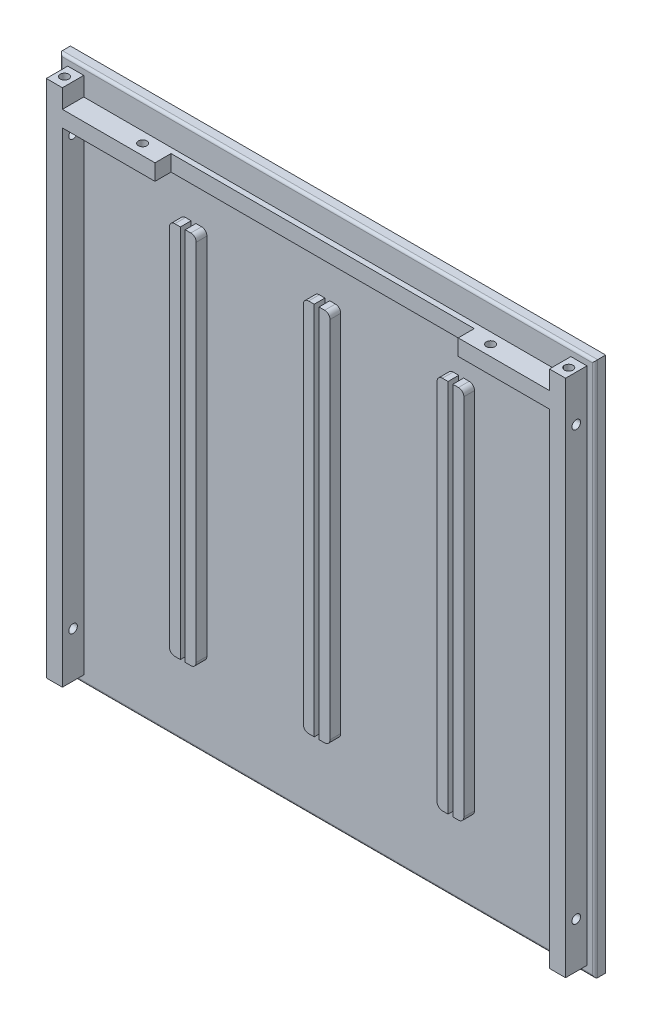
from build123d import *

# Parameters (mm, degrees)
ESQUISSE1_W                 = 200
ESQUISSE1_H                 = 200
BOSS_EXTRU_PAROIE_DEPTH     = 4
BOSS_EXTRU_BORDS_DEPTH      = 8
BOSS_EXTRU_GLISSIERES_DEPTH = 4
CONG_1_R                    = 1
ESQUISSE8_W                 = 1.8
ESQUISSE8_H                 = 180
ENL_V_MAT_EXTRU_6_DEPTH     = 9
ESQUISSE5_R                 = 1.6
ENL_V_MAT_EXTRU_2_DEPTH     = 10
ESQUISSE6_R                 = 1.6
ENL_V_MAT_EXTRU_3_DEPTH     = 10
ESQUISSE7_R                 = 1.6
ENL_V_MAT_EXTRU_4_DEPTH     = 10
ESQUISSE10_R                = 1.6
ENL_V_MAT_EXTRU_8_DEPTH     = 10
ESQUISSE11_W                = 113.303164178
ESQUISSE11_H                = 6
ENL_V_MAT_EXTRU_9_DEPTH     = 6
ESQUISSE9_R                 = 1.6
ENL_V_MAT_EXTRU_10_DEPTH    = 10


with BuildPart() as part:
    # Esquisse1 → Boss.-Extru. Paroie (new body)
    with BuildSketch(Plane.XY):
        with Locations((100, 100)):
            Rectangle(ESQUISSE1_W, ESQUISSE1_H)
    extrude(amount=BOSS_EXTRU_PAROIE_DEPTH)

    # Esquisse4 → Boss.-Extru. Bords (add)
    with BuildSketch(Plane.XY.offset(4)):
        Polygon((3, 3), (9, 3), (9, 184), (191, 184), (191, 3), (197, 3), (197, 197), (191, 197), (191, 190), (9, 190), (9, 197), (3, 197), align=None)
    extrude(amount=BOSS_EXTRU_BORDS_DEPTH)

    # Esquisse2 → Boss.-Extru. Glissieres (add)
    with BuildSketch(Plane.XY.offset(4)):
        with BuildLine():
            Line((47, 170), (53, 170))
            ThreePointArc((53, 170), (54.414213562, 169.414213562), (55, 168))
            Line((55, 168), (55, 32))
            ThreePointArc((55, 32), (54.414213562, 30.585786438), (53, 30))
            Line((53, 30), (47, 30))
            ThreePointArc((47, 30), (45.585786438, 30.585786438), (45, 32))
            Line((45, 32), (45, 168))
            ThreePointArc((45, 168), (45.585786438, 169.414213562), (47, 170))
        make_face()
        with BuildLine():
            Line((97, 170), (103, 170))
            ThreePointArc((103, 170), (104.414213562, 169.414213562), (105, 168))
            Line((105, 168), (105, 32))
            ThreePointArc((105, 32), (104.414213562, 30.585786438), (103, 30))
            Line((103, 30), (97, 30))
            ThreePointArc((97, 30), (95.585786438, 30.585786438), (95, 32))
            Line((95, 32), (95, 168))
            ThreePointArc((95, 168), (95.585786438, 169.414213562), (97, 170))
        make_face()
        with BuildLine():
            Line((147, 170), (153, 170))
            ThreePointArc((153, 170), (154.414213562, 169.414213562), (155, 168))
            Line((155, 168), (155, 32))
            ThreePointArc((155, 32), (154.414213562, 30.585786438), (153, 30))
            Line((153, 30), (147, 30))
            ThreePointArc((147, 30), (145.585786438, 30.585786438), (145, 32))
            Line((145, 32), (145, 168))
            ThreePointArc((145, 168), (145.585786438, 169.414213562), (147, 170))
        make_face()
    extrude(amount=BOSS_EXTRU_GLISSIERES_DEPTH)

    # Congé1
    cong_1_edges = [part.edges().sort_by_distance(p)[0] for p in [
        (200, 100, 4),
        (100, 200, 4),
        (0, 100, 4),
        (100, 0, 4),
    ]]
    fillet(cong_1_edges, radius=CONG_1_R)

    # Esquisse8 → Enlèv. mat.-Extru.6 (cut, through all)
    with BuildSketch(Plane.XY.offset(4)):
        with Locations((100, 85)):
            Rectangle(ESQUISSE8_W, ESQUISSE8_H)
        with Locations((150, 85)):
            Rectangle(ESQUISSE8_W, ESQUISSE8_H)
        with Locations((50, 85)):
            Rectangle(ESQUISSE8_W, ESQUISSE8_H)
    extrude(amount=ENL_V_MAT_EXTRU_6_DEPTH, mode=Mode.SUBTRACT)

    # Esquisse5 → Enlèv. mat.-Extru.2 (cut)
    with BuildSketch(Plane.ZY.offset(-3)):
        with Locations((8, 180)):
            Circle(ESQUISSE5_R)
        with Locations((8, 20)):
            Circle(ESQUISSE5_R)
    extrude(amount=-ENL_V_MAT_EXTRU_2_DEPTH, mode=Mode.SUBTRACT)

    # Esquisse6 → Enlèv. mat.-Extru.3 (cut)
    with BuildSketch(Plane(origin=(197, 0, 0), x_dir=(0, 0, -1), z_dir=(1, 0, 0))):
        with Locations((-8, 180)):
            Circle(ESQUISSE6_R)
        with Locations((-8, 20)):
            Circle(ESQUISSE6_R)
    extrude(amount=-ENL_V_MAT_EXTRU_3_DEPTH, mode=Mode.SUBTRACT)

    # Esquisse7 → Enlèv. mat.-Extru.4 (cut)
    with BuildSketch(Plane.XZ.offset(-184)):
        with Locations((35, 8)):
            Circle(ESQUISSE7_R)
        with Locations((165, 8)):
            Circle(ESQUISSE7_R)
    extrude(amount=-ENL_V_MAT_EXTRU_4_DEPTH, mode=Mode.SUBTRACT)

    # Esquisse10 → Enlèv. mat.-Extru.8 (cut)
    with BuildSketch(Plane(origin=(0, 3, 0), x_dir=(-1, 0, 0), z_dir=(0, -1, 0))):
        with Locations((-194.2, -8)):
            Circle(ESQUISSE10_R)
        with Locations((-5.8, -8)):
            Circle(ESQUISSE10_R)
    extrude(amount=-ENL_V_MAT_EXTRU_8_DEPTH, mode=Mode.SUBTRACT)

    # Esquisse11 → Enlèv. mat.-Extru.9 (cut)
    with BuildSketch(Plane.XY.offset(12)):
        with Locations((100.248809194, 187)):
            Rectangle(ESQUISSE11_W, ESQUISSE11_H)
    extrude(amount=-ENL_V_MAT_EXTRU_9_DEPTH, mode=Mode.SUBTRACT)

    # Esquisse9 → Enlèv. mat.-Extru.10 (cut)
    with BuildSketch(Plane(origin=(0, 197, 0), x_dir=(1, 0, 0), z_dir=(0, 1, 0))):
        with Locations((194.2, -8)):
            Circle(ESQUISSE9_R)
        with Locations((5.8, -8)):
            Circle(ESQUISSE9_R)
    extrude(amount=-ENL_V_MAT_EXTRU_10_DEPTH, mode=Mode.SUBTRACT)


solid = part.part
